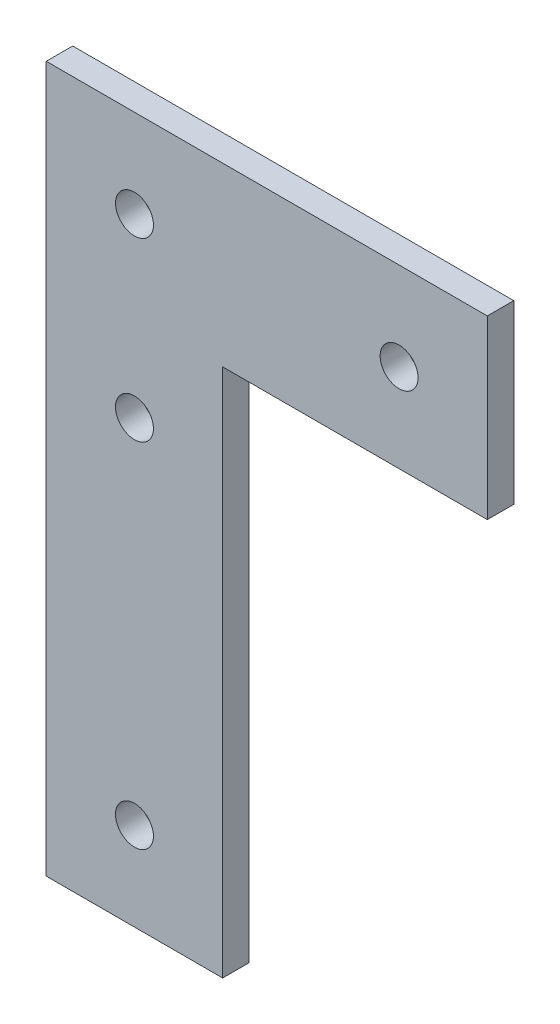
from build123d import *

# Parameters (mm, degrees)
SKETCH1_R      = 2.15
EXTRUDE1_DEPTH = 3


with BuildPart() as part:
    # Sketch1 → Extrude1 (new body)
    with BuildSketch(Plane.XY):
        Polygon((-300.61212976, 147.905049365), (-350.61212976, 147.905049365), (-350.61212976, 127.905049365), (-350.61212976, 67.905049365), (-330.61212976, 67.905049365), (-330.61212976, 127.905049365), (-300.61212976, 127.905049365), align=None)
        with Locations((-340.61212976, 77.905049365)):
            Circle(SKETCH1_R, mode=Mode.SUBTRACT)
        with Locations((-340.61212976, 117.905049365)):
            Circle(SKETCH1_R, mode=Mode.SUBTRACT)
        with Locations((-340.61212976, 137.905049365)):
            Circle(SKETCH1_R, mode=Mode.SUBTRACT)
        with Locations((-310.61212976, 137.905049365)):
            Circle(SKETCH1_R, mode=Mode.SUBTRACT)
    extrude(amount=EXTRUDE1_DEPTH)


solid = part.part
